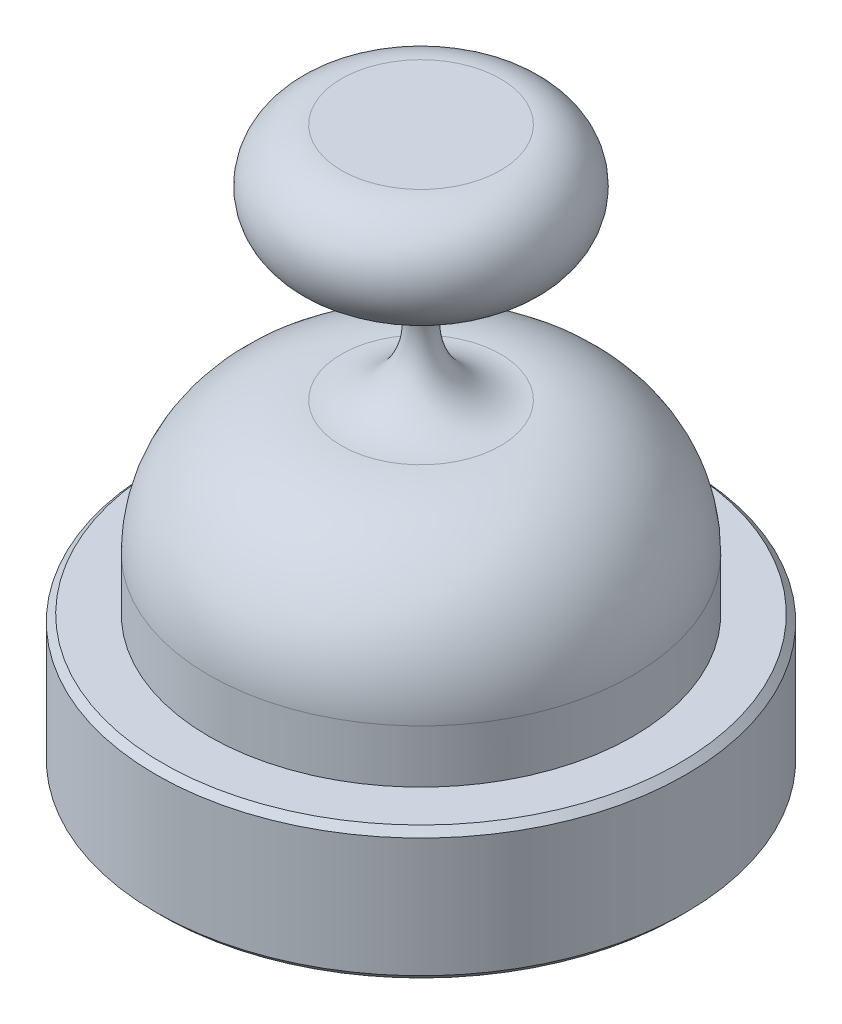
from build123d import *

# Parameters (mm, degrees)
ESQUISSE2_R      = 100
EXTRUSION1_DEPTH = 50
CHANFREIN1_SIZE  = 2.5


with BuildPart() as part:
    # Esquisse1 → Révolution2 (revolve)
    with BuildSketch(Plane.XY):
        with BuildLine():
            Line((0, 160), (-30, 160))
            ThreePointArc((-30, 160), (-50, 140), (-30, 120))
            ThreePointArc((-30, 120), (-5, 95), (-30, 70))
            ThreePointArc((-30, 70), (-65.355339059, 55.355339059), (-80, 20))
            Line((-80, 20), (-80, 0))
            Line((-80, 0), (0, 0))
            Line((0, 0), (0, 160))
        make_face()
    revolve(axis=Axis((0, 160, 0), (0, -1, 0)))

    # Esquisse2 → Extrusion1 (add)
    with BuildSketch(Plane.XZ):
        Circle(ESQUISSE2_R)
    extrude(amount=EXTRUSION1_DEPTH)

    # Chanfrein1
    chanfrein1_edges = [part.edges().sort_by_distance(p)[0] for p in [
        (-100, 0, 0),
        (-100, -50, 0),
    ]]
    chamfer(chanfrein1_edges, length=CHANFREIN1_SIZE)


solid = part.part
